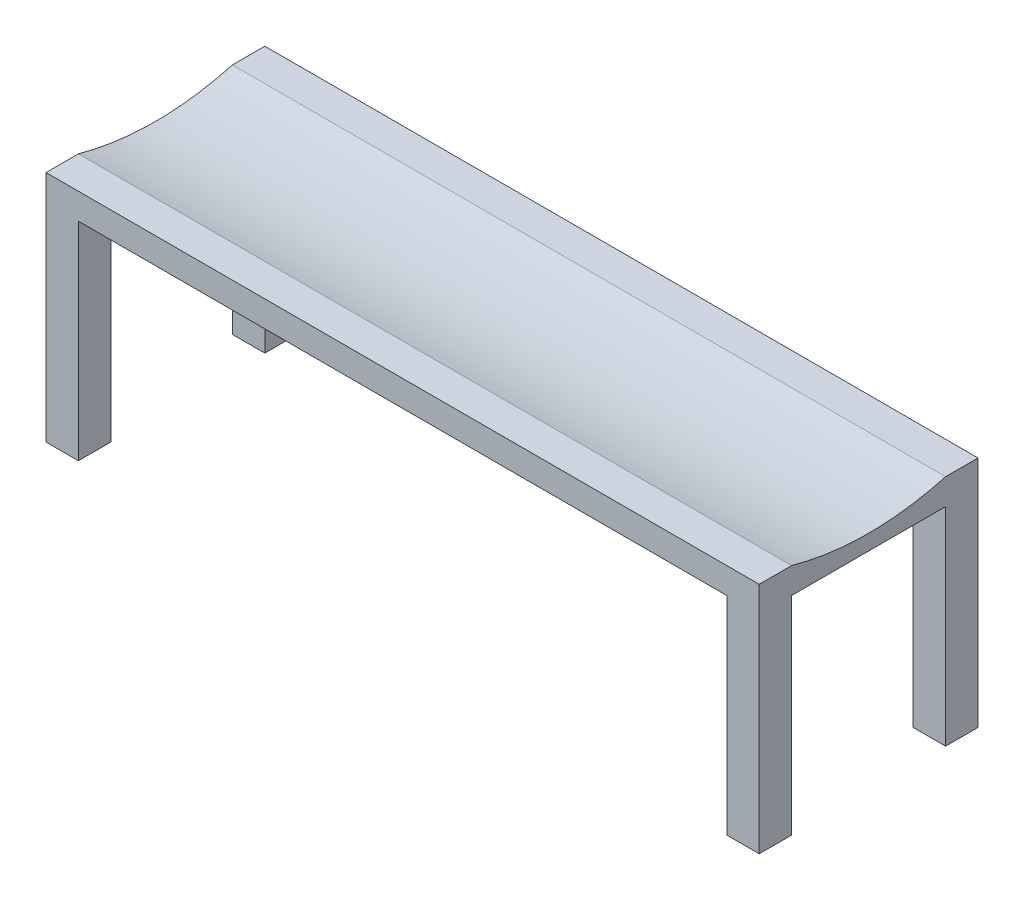
from build123d import *

# Parameters (mm, degrees)
SKETCH1_W               = 139.7
SKETCH1_H               = 42.8625
BOSS_EXTRUDE1_DEPTH     = 45.72
CUT_EXTRUDE2_DEPTH      = 40.64
CUT_EXTRUDE3_DEPTH      = 1
CUT_EXTRUDE3_DEPTH_BACK = 139.7


with BuildPart() as part:
    # Sketch1 → Boss-Extrude1 (new body)
    with BuildSketch(Plane(origin=(0, 0, 0), x_dir=(1, 0, 0), z_dir=(0, 1, 0))):
        with Locations((92.537965446, 28.29525747)):
            Rectangle(SKETCH1_W, SKETCH1_H)
    extrude(amount=BOSS_EXTRUDE1_DEPTH)

    # Sketch7 → Cut-Extrude2 (cut)
    with BuildSketch(Plane(origin=(0, 0, 0), x_dir=(1, 0, 0), z_dir=(0, 1, 0))):
        Polygon((22.687965446, 43.37650747), (29.037965446, 43.37650747), (29.037965446, 49.72650747), (156.037965446, 49.72650747), (156.037965446, 43.37650747), (162.387965446, 43.37650747), (162.387965446, 13.21400747), (156.037965446, 13.21400747), (156.037965446, 6.86400747), (29.037965446, 6.86400747), (29.037965446, 13.21400747), (22.687965446, 13.21400747), align=None)
    extrude(amount=CUT_EXTRUDE2_DEPTH, mode=Mode.SUBTRACT)

    # Sketch8 → Cut-Extrude3 (cut, two sides)
    with BuildSketch(Plane.ZY.offset(-22.687965446)) as cut_extrude3_sk:
        with BuildLine():
            Line((-13.21400747, 45.72), (-43.37650747, 45.72))
            add(Edge.make_bspline(
                [(-43.37650747, 45.72), (-28.29525747, 41.58097799), (-13.21400747, 45.72)],
                knots=[0, 0, 0, 1, 1, 1], degree=2))
        make_face()
    extrude(amount=CUT_EXTRUDE3_DEPTH, mode=Mode.SUBTRACT)
    extrude(cut_extrude3_sk.sketch, amount=-CUT_EXTRUDE3_DEPTH_BACK, mode=Mode.SUBTRACT)


solid = part.part
